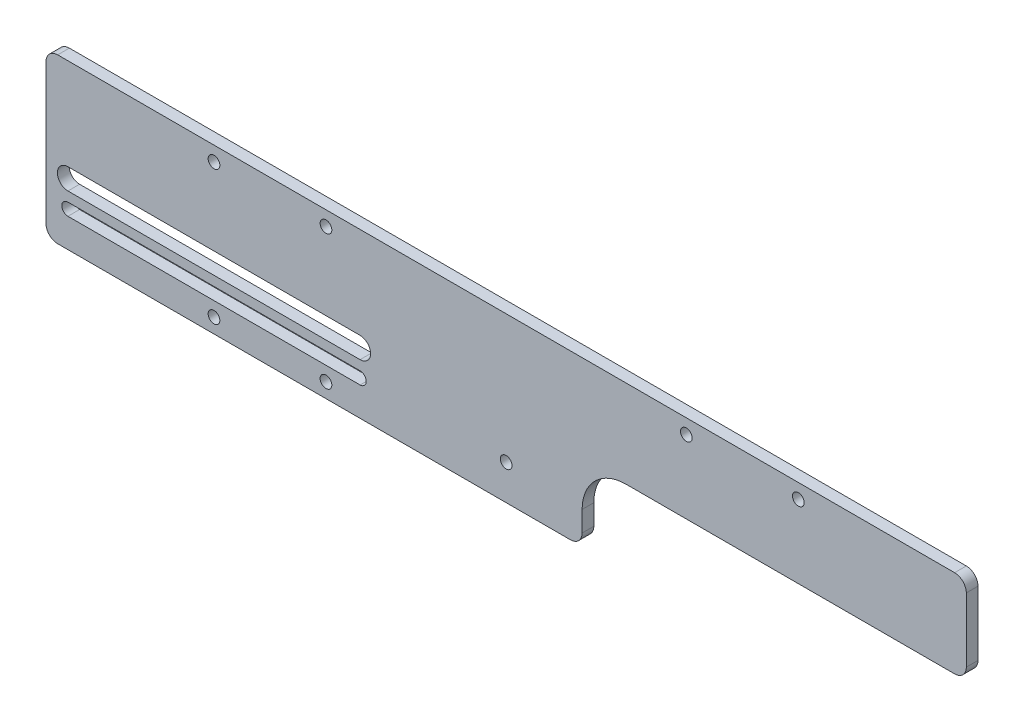
from build123d import *

# Parameters (mm, degrees)
SKETCH_1_R          = 2
EXTRUDE_1_DEPTH     = 4
CUT_EXTRUDE_1_DEPTH = 4
EXTRUDE_2_DEPTH     = 4
EXTRUDE_3_DEPTH     = 4
SKETCH_18_R         = 2
CUT_EXTRUDE_2_DEPTH = 5
CUT_EXTRUDE_3_DEPTH = 5


with BuildPart() as part:
    # 草图1 → 凸台-拉伸1 (new body)
    with BuildSketch(Plane.XY):
        with BuildLine():
            Line((153.5, -28), (-153.5, -28))
            ThreePointArc((-153.5, -28), (-156.328427125, -26.828427125), (-157.5, -24))
            Line((-157.5, -24), (-157.5, 24))
            ThreePointArc((-157.5, 24), (-156.328427125, 26.828427125), (-153.5, 28))
            Line((-153.5, 28), (153.5, 28))
            ThreePointArc((153.5, 28), (156.328427125, 26.828427125), (157.5, 24))
            Line((157.5, 24), (157.5, -24))
            ThreePointArc((157.5, -24), (156.328427125, -26.828427125), (153.5, -28))
        make_face()
        with Locations((-100, 23)):
            Circle(SKETCH_1_R, mode=Mode.SUBTRACT)
        with Locations((-61.67, 23)):
            Circle(SKETCH_1_R, mode=Mode.SUBTRACT)
        with Locations((-100, -23)):
            Circle(SKETCH_1_R, mode=Mode.SUBTRACT)
        with Locations((-61.67, -23)):
            Circle(SKETCH_1_R, mode=Mode.SUBTRACT)
        with Locations((100, -23)):
            Circle(SKETCH_1_R, mode=Mode.SUBTRACT)
        with Locations((61.67, -23)):
            Circle(SKETCH_1_R, mode=Mode.SUBTRACT)
        with Locations((61.67, 23)):
            Circle(SKETCH_1_R, mode=Mode.SUBTRACT)
        with Locations((100, 23)):
            Circle(SKETCH_1_R, mode=Mode.SUBTRACT)
        with BuildLine():
            Line((-150, -13.9), (-50, -13.9))
            ThreePointArc((-50, -13.9), (-47.9, -16), (-50, -18.1))
            Line((-50, -18.1), (-150, -18.1))
            ThreePointArc((-150, -18.1), (-152.1, -16), (-150, -13.9))
        make_face(mode=Mode.SUBTRACT)
    extrude(amount=EXTRUDE_1_DEPTH)

    # 草图2 → 切除-拉伸1 (cut)
    with BuildSketch(Plane.XY.offset(4)):
        with BuildLine():
            Line((0, -12), (0, -24))
            ThreePointArc((0, -24), (-1.171572875, -26.828427125), (-4, -28))
            Line((-4, -28), (0, -28))
            Line((0, -28), (157.5, -28))
            Line((157.5, -28), (157.5, -2))
            Line((157.5, -2), (157.5, 2))
            ThreePointArc((157.5, 2), (156.328427125, -0.828427125), (153.5, -2))
            Line((153.5, -2), (146.462792112, -2))
            Line((146.462792112, -2), (108, -2))
            Line((108, -2), (10, -2))
            ThreePointArc((10, -2), (2.928932188, -4.928932188), (0, -12))
        make_face()
    extrude(amount=-CUT_EXTRUDE_1_DEPTH, mode=Mode.SUBTRACT)

    # 草图3 → 凸台-拉伸2 (add)
    with BuildSketch(Plane.XY.offset(4)):
        with BuildLine():
            Line((-4, 28), (-4, -28))
            ThreePointArc((-4, -28), (-1.171572875, -26.828427125), (0, -24))
            Line((0, -24), (0, -12))
            ThreePointArc((0, -12), (2.928932188, -4.928932188), (10, -2))
            Line((10, -2), (26, -2))
            Line((26, -2), (26, 24))
            ThreePointArc((26, 24), (27.171572875, 26.828427125), (30, 28))
            Line((30, 28), (26, 28))
            Line((26, 28), (-4, 28))
        make_face()
        with BuildLine():
            ThreePointArc((0, -24), (-1.171572875, -26.828427125), (-4, -28))
            Line((-4, -28), (22, -28))
            ThreePointArc((22, -28), (24.828427125, -26.828427125), (26, -24))
            Line((26, -24), (26, -2))
            Line((26, -2), (10, -2))
            ThreePointArc((10, -2), (2.928932188, -4.928932188), (0, -12))
            Line((0, -12), (0, -24))
        make_face()
    extrude(amount=-EXTRUDE_2_DEPTH)

    # 草图17 → 凸台-拉伸3 (add)
    with BuildSketch(Plane.XY.offset(4)):
        with BuildLine():
            Line((26, -2), (26, -8.742458912))
            Line((26, -8.742458912), (26, -17))
            ThreePointArc((26, -17), (30.393398282, -6.393398282), (41, -2))
            Line((41, -2), (26, -2))
        make_face()
    extrude(amount=-EXTRUDE_3_DEPTH)

    # 草图18 → 切除-拉伸2 (cut, through all)
    with BuildSketch(Plane.XY.offset(4)):
        with Locations((0, -16)):
            Circle(SKETCH_18_R)
    extrude(amount=-CUT_EXTRUDE_2_DEPTH, mode=Mode.SUBTRACT)

    # 草图19 → 切除-拉伸3 (cut, through all)
    with BuildSketch(Plane.XY.offset(4)):
        with BuildLine():
            Line((-50, -10.6), (-150, -10.6))
            ThreePointArc((-150, -10.6), (-153.6, -7), (-150, -3.4))
            Line((-150, -3.4), (-50, -3.4))
            ThreePointArc((-50, -3.4), (-46.4, -7), (-50, -10.6))
        make_face()
    extrude(amount=-CUT_EXTRUDE_3_DEPTH, mode=Mode.SUBTRACT)


solid = part.part
